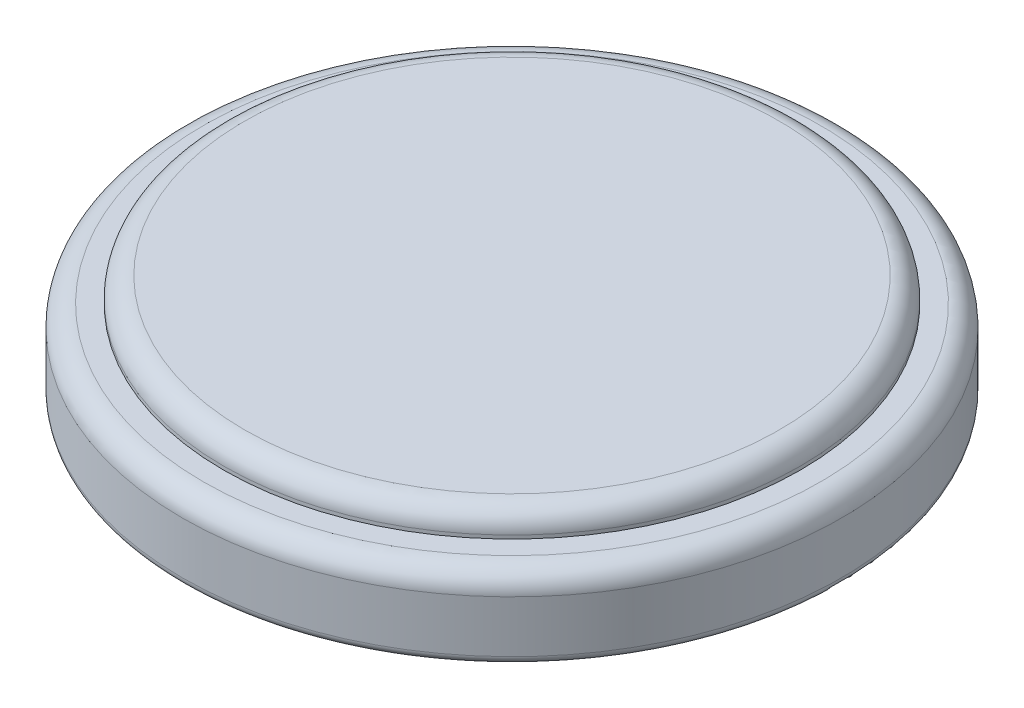
from build123d import *

# Parameters (mm, degrees)
FILLET1_R = 0.635
FILLET2_R = 0.254


with BuildPart() as part:
    # Sketch1 → Revolve1 (revolve)
    with BuildSketch(Plane.XY):
        Polygon((0, 0), (0, 3.2), (8.75, 3.2), (8.75, 2.46), (10, 2.46), (10, 0), align=None)
    revolve(axis=Axis((0, 0, 0), (0, 1, 0)))

    # Fillet1
    fillet1_edges = [part.edges().sort_by_distance(p)[0] for p in [
        (-10, 2.46, 0),
        (-8.75, 3.2, 0),
    ]]
    fillet(fillet1_edges, radius=FILLET1_R)

    # Fillet2
    fillet2_edges = [part.edges().sort_by_distance(p)[0] for p in [
        (-10, 0, 0),
    ]]
    fillet(fillet2_edges, radius=FILLET2_R)


solid = part.part
